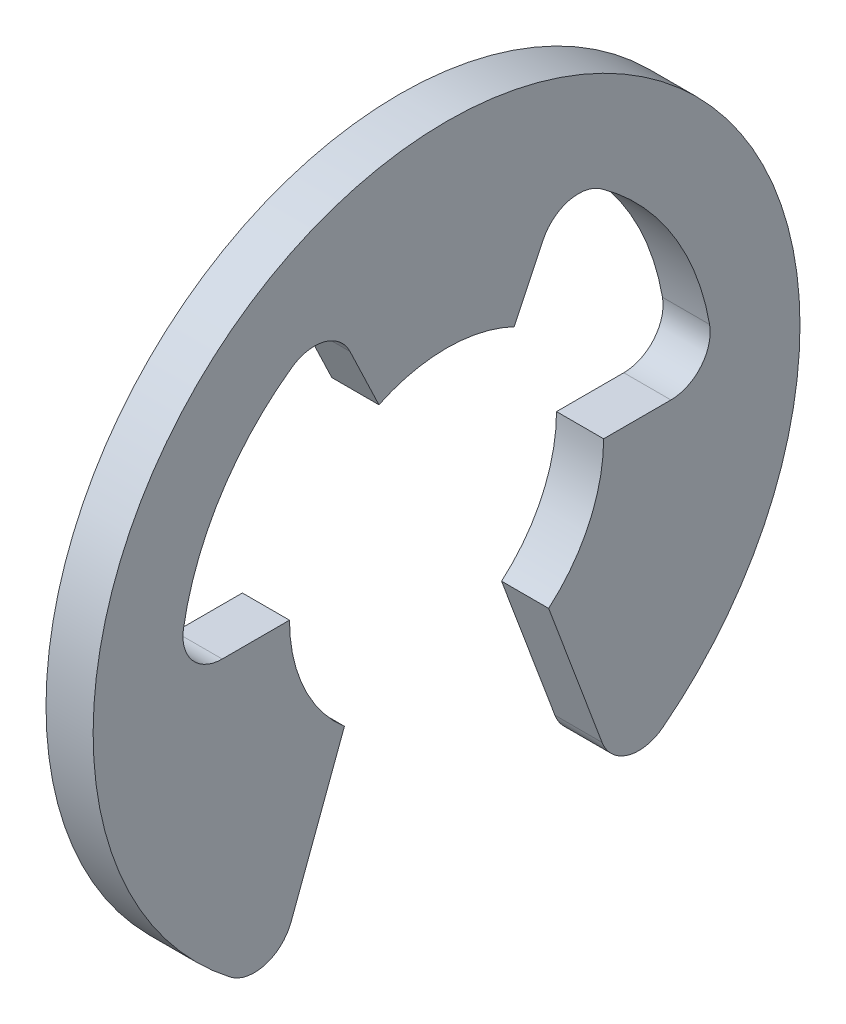
from build123d import *

# Parameters (mm, degrees)
BOSS_EXTRUDE1_DEPTH = 0.6


with BuildPart() as part:
    # Sketch1 → Boss-Extrude1 (new body)
    with BuildSketch(Plane(origin=(0, 0, 0), x_dir=(0, 0, -1), z_dir=(1, 0, 0))):
        with BuildLine():
            Line((2.856571371, 0), (2, 0))
            ThreePointArc((2, 0), (1.816590212, -0.836660027), (1.3, -1.519868415))
            Line((1.3, -1.519868415), (1.979902452, -3.338350127))
            ThreePointArc((1.979902452, -3.338350127), (2.311420831, -3.644163179), (2.754268365, -3.558652241))
            ThreePointArc((2.754268365, -3.558652241), (0, 4.5), (-2.754268365, -3.558652241))
            ThreePointArc((-2.754268365, -3.558652241), (-2.311420831, -3.644163179), (-1.979902452, -3.338350127))
            Line((-1.979902452, -3.338350127), (-1.3, -1.519868415))
            ThreePointArc((-1.3, -1.519868415), (-1.816590212, -0.836660027), (-2, 0))
            Line((-2, 0), (-2.856571371, 0))
            ThreePointArc((-2.856571371, 0), (-3.239392118, 0.17836624), (-3.349083677, 0.586206897))
            ThreePointArc((-3.349083677, 0.586206897), (-2.875474594, 1.814289354), (-1.970919405, 2.770465069))
            ThreePointArc((-1.970919405, 2.770465069), (-1.555584997, 2.847039011), (-1.229785674, 2.578299284))
            Line((-1.229785674, 2.578299284), (-0.861022194, 1.805170569))
            ThreePointArc((-0.861022194, 1.805170569), (0, 2), (0.861022194, 1.805170569))
            Line((0.861022194, 1.805170569), (1.229785674, 2.578299284))
            ThreePointArc((1.229785674, 2.578299284), (1.555584997, 2.847039011), (1.970919405, 2.770465069))
            ThreePointArc((1.970919405, 2.770465069), (2.875474594, 1.814289354), (3.349083677, 0.586206897))
            ThreePointArc((3.349083677, 0.586206897), (3.239392118, 0.17836624), (2.856571371, 0))
        make_face()
    extrude(amount=BOSS_EXTRUDE1_DEPTH)


solid = part.part
